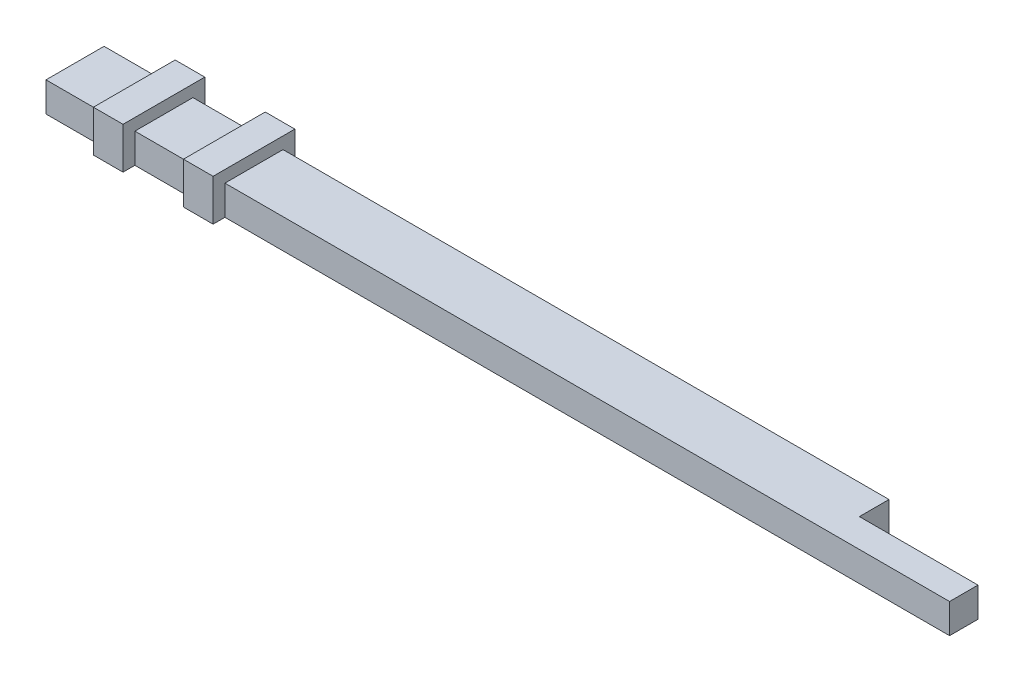
from build123d import *

# Parameters (mm, degrees)
BOSS_EXTRUDE1_DEPTH = 5
SKETCH2_W           = 13.8
SKETCH2_H           = 7
BOSS_EXTRUDE2_DEPTH = 5
SKETCH3_W           = 13.8
SKETCH3_H           = 7
BOSS_EXTRUDE3_DEPTH = 5


with BuildPart() as part:
    # Sketch1 → Boss-Extrude1 (new body)
    with BuildSketch(Plane(origin=(0, 0, 0), x_dir=(1, 0, 0), z_dir=(0, 1, 0))):
        Polygon((132.481495242, 9.8), (132.481495242, 4.8), (142.481495242, 4.8), (152.5, 4.8), (152.5, 0), (142.5, 0), (0, 0), (0, 9.8), align=None)
    extrude(amount=BOSS_EXTRUDE1_DEPTH)

    # Sketch2 → Boss-Extrude2 (add)
    with BuildSketch(Plane.ZY.offset(-10)):
        with Locations((-4.9, 3.5)):
            Rectangle(SKETCH2_W, SKETCH2_H)
    extrude(amount=-BOSS_EXTRUDE2_DEPTH)

    # Sketch3 → Boss-Extrude3 (add)
    with BuildSketch(Plane(origin=(30.2, 0, 0), x_dir=(0, 0, -1), z_dir=(1, 0, 0))):
        with Locations((4.9, 3.5)):
            Rectangle(SKETCH3_W, SKETCH3_H)
    extrude(amount=-BOSS_EXTRUDE3_DEPTH)


solid = part.part
